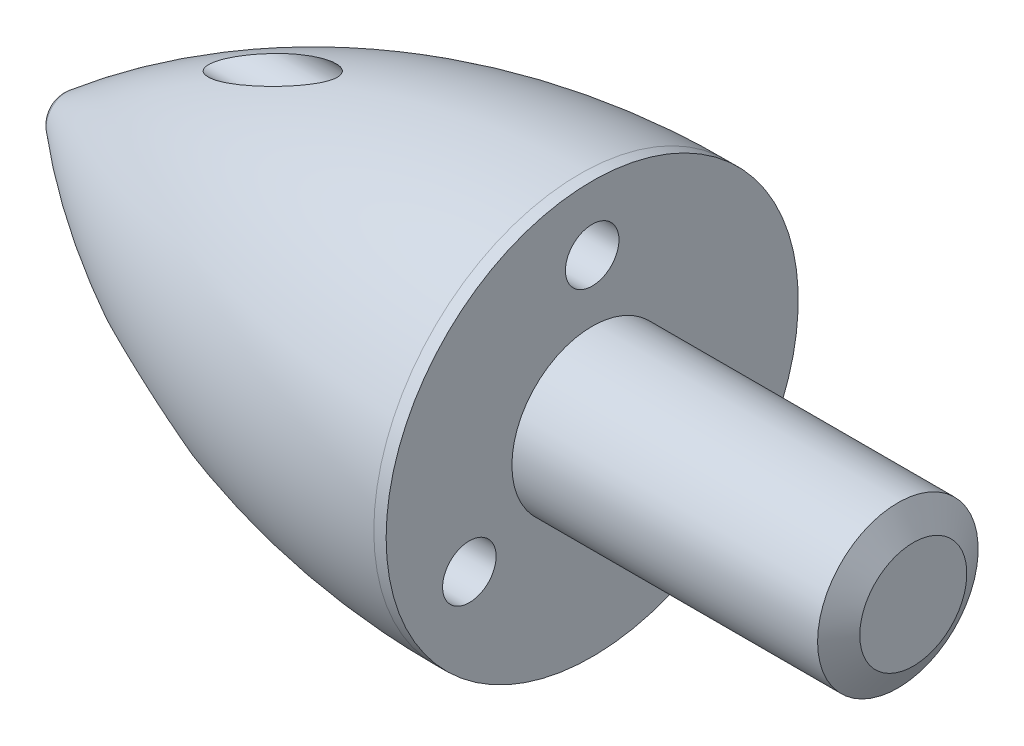
from build123d import *

# Parameters (mm, degrees)
CIRPATTERN1_COUNT = 3


with BuildPart() as part:
    # Sketch1 → Revolve1 (revolve)
    with BuildSketch(Plane.XY):
        with BuildLine():
            Line((0, 3.85), (0, 1.5))
            Line((0, 1.5), (5.711324865, 1.5))
            Line((5.711324865, 1.5), (6, 1))
            Line((6, 1), (6, 0))
            Line((6, 0), (-10, 0))
            ThreePointArc((-10, 0), (-9.952671274, 0.212341041), (-9.819645129, 0.384482759))
            ThreePointArc((-9.819645129, 0.384482759), (-5.328465382, 2.957041529), (-0.230291267, 3.85))
            Line((-0.230291267, 3.85), (0, 3.85))
        make_face()
    revolve(axis=Axis((-88.99, 0, 0), (1, 0, 0)))

    # Sketch5 → Ø1.0mm Dowel Hole1 (revolve, cut)
    with BuildSketch(Plane(origin=(0, 2.65, 0), x_dir=(0, 0, -1), z_dir=(0, 1, 0))):
        Polygon((0, 0), (0, 8.80043031), (0.5, 8.5), (0.5, 0), align=None)
    f_1_0mm_dowel_hole1 = revolve(axis=Axis((6.35, 2.65, 0), (-1, 0, 0)), mode=Mode.SUBTRACT)

    # CirPattern1: Ø1.0mm Dowel Hole1 ×3 about axis
    cirpattern1_axis = Axis((0, 0, 0), (1, 0, 0))
    for i in range(1, CIRPATTERN1_COUNT):
        add(f_1_0mm_dowel_hole1.rotate(cirpattern1_axis, i * 360 / CIRPATTERN1_COUNT), mode=Mode.SUBTRACT)


solid = part.part
